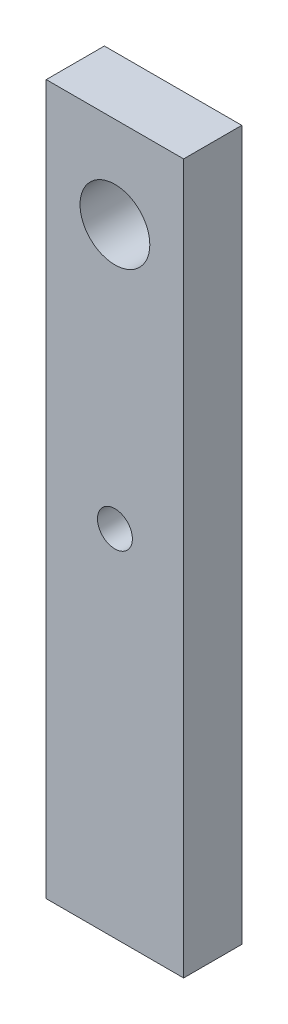
from build123d import *

# Parameters (mm, degrees)
SKETCH1_W           = 23.626462912
SKETCH1_H           = 121.978482936
SKETCH1_R           = 3
SKETCH1_R_2         = 6
BOSS_EXTRUDE1_DEPTH = 10


with BuildPart() as part:
    # Sketch1 → Boss-Extrude1 (new body)
    with BuildSketch(Plane.XY):
        Rectangle(SKETCH1_W, SKETCH1_H)
        Circle(SKETCH1_R, mode=Mode.SUBTRACT)
        with Locations((0, 45.299488294)):
            Circle(SKETCH1_R_2, mode=Mode.SUBTRACT)
    extrude(amount=BOSS_EXTRUDE1_DEPTH)


solid = part.part
